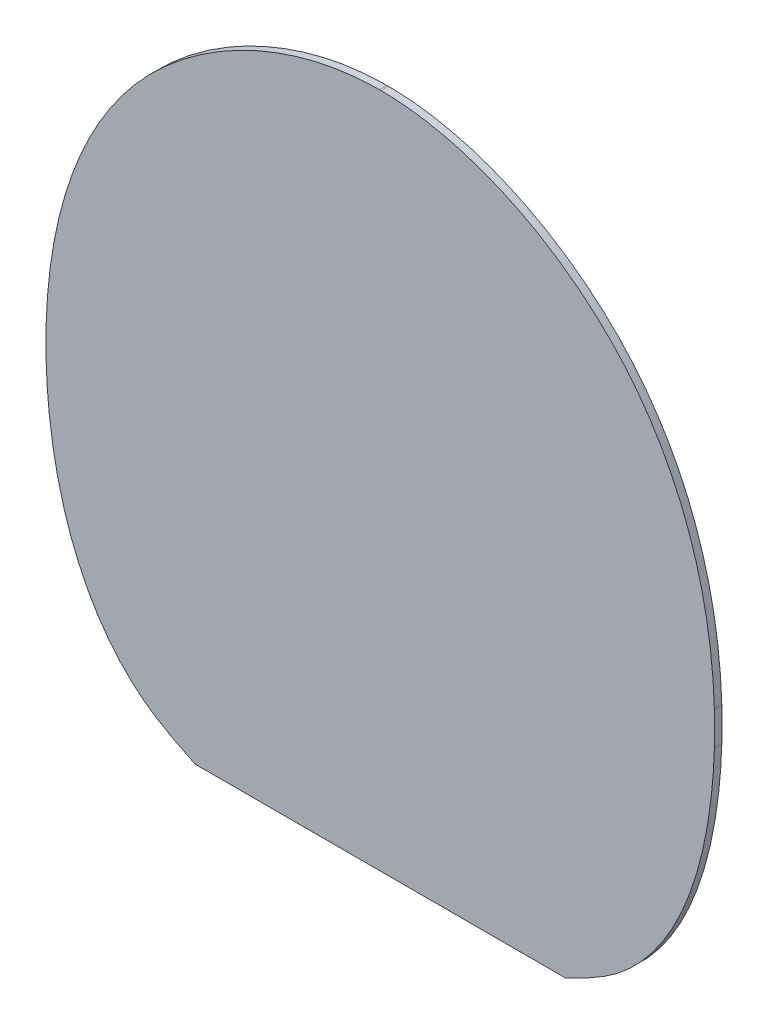
from build123d import *

# Parameters (mm, degrees)
BOSS_EXTRUDE2_DEPTH = 2


with BuildPart() as part:
    # Sketch1 → Boss-Extrude2 (new body)
    with BuildSketch(Plane.XY):
        with BuildLine():
            Line((0, 200.595525294), (0, 191.65032035))
            add(Edge.make_bspline(
                [(40.101032839, 117.840442967), (35.50049979, 120.099470076), (28.290809806, 123.632993412), (7.151679686, 142.893766889), (0.6682659, 169.378414193), (0, 191.65032035)],
                knots=[0.15765272, 0.15765272, 0.15765272, 0.15765272, 0.211663242, 0.246387134, 0.464099584, 0.464099584, 0.464099584, 0.464099584], degree=3))
            Line((40.101032839, 117.840442967), (139.898967161, 117.840442967))
            add(Edge.make_bspline(
                [(139.898967161, 117.840442967), (144.49950021, 120.099470076), (151.709190194, 123.632993412), (172.848320314, 142.893766889), (179.3317341, 169.378414193), (180, 191.65032035)],
                knots=[0.15765272, 0.15765272, 0.15765272, 0.15765272, 0.211663242, 0.246387134, 0.464099584, 0.464099584, 0.464099584, 0.464099584], degree=3))
            Line((180, 191.65032035), (180, 200.595525294))
            add(Edge.make_bspline(
                [(180, 200.595525294), (179.179346149, 227.438302674), (163.29910964, 275.970123499), (113.184129082, 299.959310061), (90.245728189, 300)],
                knots=[0.493370629, 0.493370629, 0.493370629, 0.493370629, 0.75821873, 0.999139583, 0.999139583, 0.999139583, 0.999139583], degree=3))
            Line((90.245728189, 300), (90, 300))
            Line((90, 300), (89.754271811, 300))
            add(Edge.make_bspline(
                [(0, 200.595525294), (0.820653851, 227.438302674), (16.70089036, 275.970123499), (66.815870918, 299.959310061), (89.754271811, 300)],
                knots=[0.493370629, 0.493370629, 0.493370629, 0.493370629, 0.75821873, 0.999139583, 0.999139583, 0.999139583, 0.999139583], degree=3))
        make_face()
    extrude(amount=BOSS_EXTRUDE2_DEPTH)


solid = part.part
